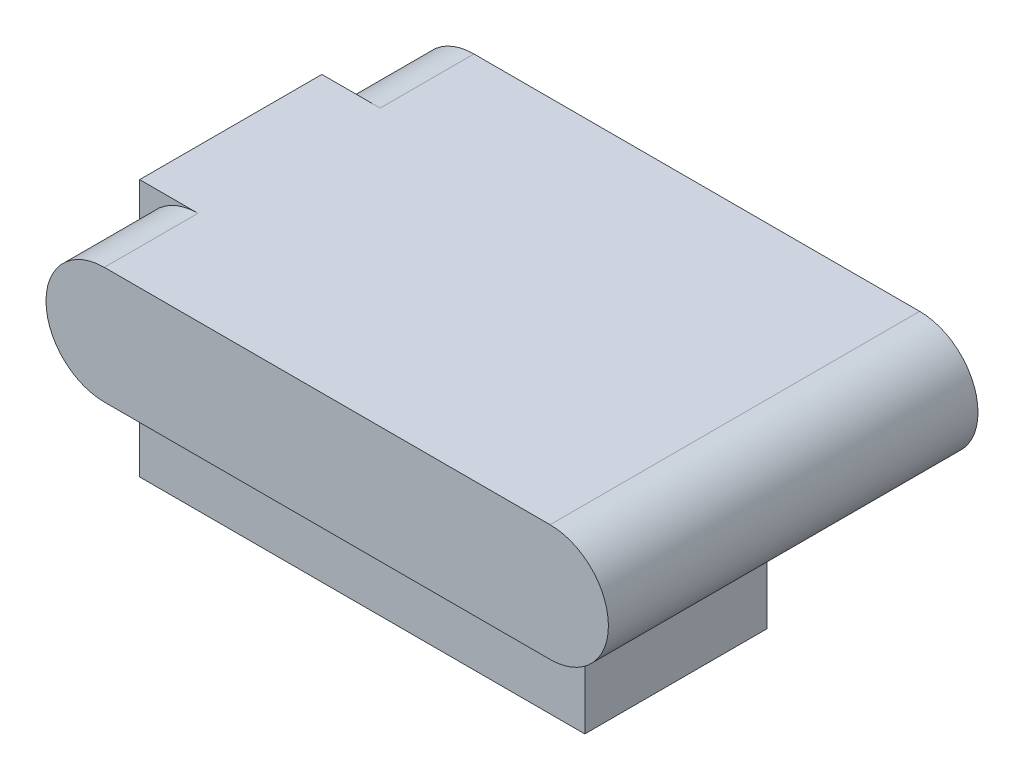
from build123d import *

# Parameters (mm, degrees)
SKETCH1_W                = 60.3758
SKETCH1_H                = 24.7142
BOSS_EXTRUDE1_DEPTH      = 34.925
BOSS_EXTRUDE2_DEPTH      = 12.7
BOSS_EXTRUDE2_DEPTH_BACK = 37.4269


with BuildPart() as part:
    # Sketch1 → Boss-Extrude1 (new body)
    with BuildSketch(Plane(origin=(0, 0, 0), x_dir=(1, 0, 0), z_dir=(0, 1, 0))):
        with Locations((30.1879, 12.3571)):
            Rectangle(SKETCH1_W, SKETCH1_H)
    extrude(amount=BOSS_EXTRUDE1_DEPTH)

    # Sketch2 → Boss-Extrude2 (add, two sides)
    with BuildSketch(Plane.XY) as boss_extrude2_sk:
        with BuildLine():
            Line((7.9121, 34.925), (68.3641, 34.925))
            ThreePointArc((68.3641, 34.925), (76.2762, 27.0129), (68.3641, 19.1008))
            Line((68.3641, 19.1008), (7.9121, 19.1008))
            ThreePointArc((7.9121, 19.1008), (0, 27.0129), (7.9121, 34.925))
        make_face()
    extrude(amount=BOSS_EXTRUDE2_DEPTH)
    extrude(boss_extrude2_sk.sketch, amount=-BOSS_EXTRUDE2_DEPTH_BACK)


solid = part.part
